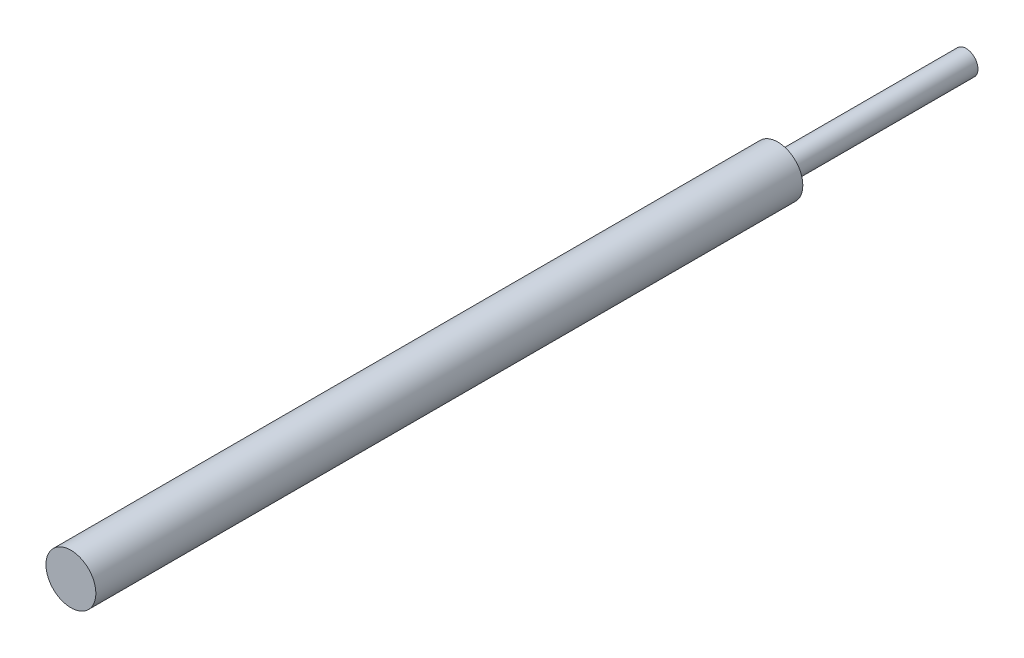
from build123d import *

# Parameters (mm, degrees)
SKETCH1_R      = 2.921
EXTRUDE1_DEPTH = 45.974
SKETCH2_R      = 6.096
EXTRUDE2_DEPTH = 172.72


with BuildPart() as part:
    # Sketch1 → Extrude1 (new body)
    with BuildSketch(Plane.XY):
        Circle(SKETCH1_R)
    extrude(amount=EXTRUDE1_DEPTH)

    # Sketch2 → Extrude2 (add)
    with BuildSketch(Plane.XY.offset(45.974)):
        Circle(SKETCH2_R)
    extrude(amount=EXTRUDE2_DEPTH)


solid = part.part
